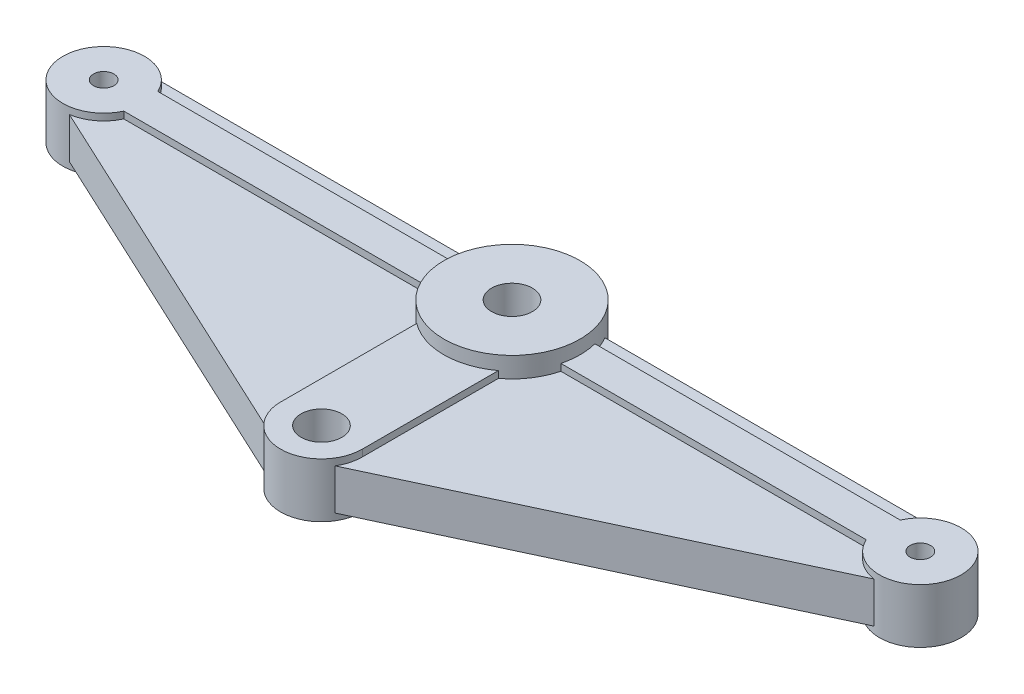
from build123d import *
from build123d.topology import SkipClean

# Parameters (mm, degrees)
SKETCH1_R      = 0.75
SKETCH1_R_2    = 1.5
EXTRUDE1_DEPTH = 1.5
SKETCH2_R      = 0.75
SKETCH2_R_2    = 1.5
EXTRUDE2_DEPTH = 2
SKETCH3_R      = 5
SKETCH3_R_2    = 1.5
EXTRUDE3_DEPTH = 3


with BuildPart() as part:
    # Sketch1 → Extrude1 (new body, symmetric)
    with BuildSketch(Plane(origin=(0, 0, 0), x_dir=(1, 0, 0), z_dir=(0, 1, 0))):
        with BuildLine():
            Line((-30, 2.5), (30, 2.5))
            ThreePointArc((30, 2.5), (32.440660221, 0.541458851), (31.057213663, -2.26545785))
            Line((31.057213663, -2.26545785), (1.057213663, -16.26545785))
            ThreePointArc((1.057213663, -16.26545785), (0, -16.5), (-1.057213663, -16.26545785))
            Line((-1.057213663, -16.26545785), (-31.057213663, -2.26545785))
            ThreePointArc((-31.057213663, -2.26545785), (-32.440660221, 0.541458851), (-30, 2.5))
        make_face()
        with Locations(Location((30, 0, 0), (0, 0, 270))):  # turned: the seam where the file's is
            Circle(SKETCH1_R, mode=Mode.SUBTRACT)
        with Locations(Location((-30, 0, 0), (0, 0, 270))):  # turned: the seam where the file's is
            Circle(SKETCH1_R, mode=Mode.SUBTRACT)
        with Locations(Location((0, -14, 0), (0, 0, 270))):  # turned: the seam where the file's is
            Circle(SKETCH1_R_2, mode=Mode.SUBTRACT)
        with Locations(Location((0, 0, 0), (0, 0, 270))):  # turned: the seam where the file's is
            Circle(SKETCH1_R_2, mode=Mode.SUBTRACT)
    extrude(amount=EXTRUDE1_DEPTH, both=True)

    # Sketch2 → Extrude2 (add, symmetric)
    with SkipClean():  # keep this step's faces unmerged: merging them makes the solid invalid here
        with BuildSketch(Plane(origin=(0, 0, 0), x_dir=(1, 0, 0), z_dir=(0, 1, 0))):
            with BuildLine():
                Line((-27.272821971, 1.25), (-0.829156198, 1.25))
                ThreePointArc((-0.829156198, 1.25), (0, -1.5), (0.829156198, 1.25))
                Line((0.829156198, 1.25), (27.272821971, 1.25))
                ThreePointArc((27.272821971, 1.25), (33, 0), (27.272821971, -1.25))
                Line((27.272821971, -1.25), (3, -1.25))
                Line((3, -1.25), (3, -14))
                ThreePointArc((3, -14), (0, -17), (-3, -14))
                Line((-3, -14), (-3, -1.25))
                Line((-3, -1.25), (-27.272821971, -1.25))
                ThreePointArc((-27.272821971, -1.25), (-33, 0), (-27.272821971, 1.25))
            make_face()
            with Locations(Location((30, 0, 0), (0, 0, 270))):  # turned: the seam where the file's is
                Circle(SKETCH2_R, mode=Mode.SUBTRACT)
            with Locations(Location((0, -14, 0), (0, 0, 270))):  # turned: the seam where the file's is
                Circle(SKETCH2_R_2, mode=Mode.SUBTRACT)
            with Locations(Location((-30, 0, 0), (0, 0, 270))):  # turned: the seam where the file's is
                Circle(SKETCH2_R, mode=Mode.SUBTRACT)
        extrude(amount=EXTRUDE2_DEPTH, both=True)

    # Sketch3 → Extrude3 (add, symmetric)
    with SkipClean():  # keep this step's faces unmerged: merging them makes the solid invalid here
        with BuildSketch(Plane(origin=(0, 0, 0), x_dir=(1, 0, 0), z_dir=(0, 1, 0))):
            with Locations(Location((0, 0, 0), (0, 0, 270))):  # turned: the seam where the file's is
                Circle(SKETCH3_R)
            with Locations(Location((0, 0, 0), (0, 0, 270))):  # turned: the seam where the file's is
                Circle(SKETCH3_R_2, mode=Mode.SUBTRACT)
        extrude(amount=EXTRUDE3_DEPTH, both=True)


solid = part.part
